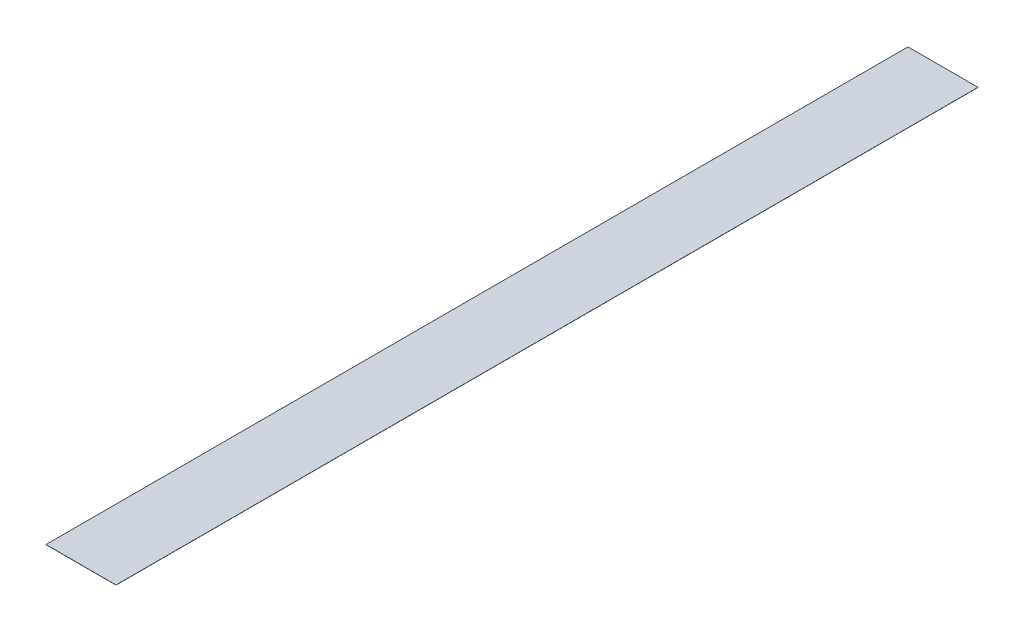
from build123d import *

# Parameters (mm, degrees)
SKETCH1_W      = 24.9
SKETCH1_H      = 306.5
EXTRUDE1_DEPTH = 0.0508


with BuildPart() as part:
    # Sketch1 → Extrude1 (new body)
    with BuildSketch(Plane(origin=(0, 0, 0), x_dir=(1, 0, 0), z_dir=(0, 1, 0))):
        Rectangle(SKETCH1_W, SKETCH1_H)
    extrude(amount=EXTRUDE1_DEPTH)


solid = part.part
